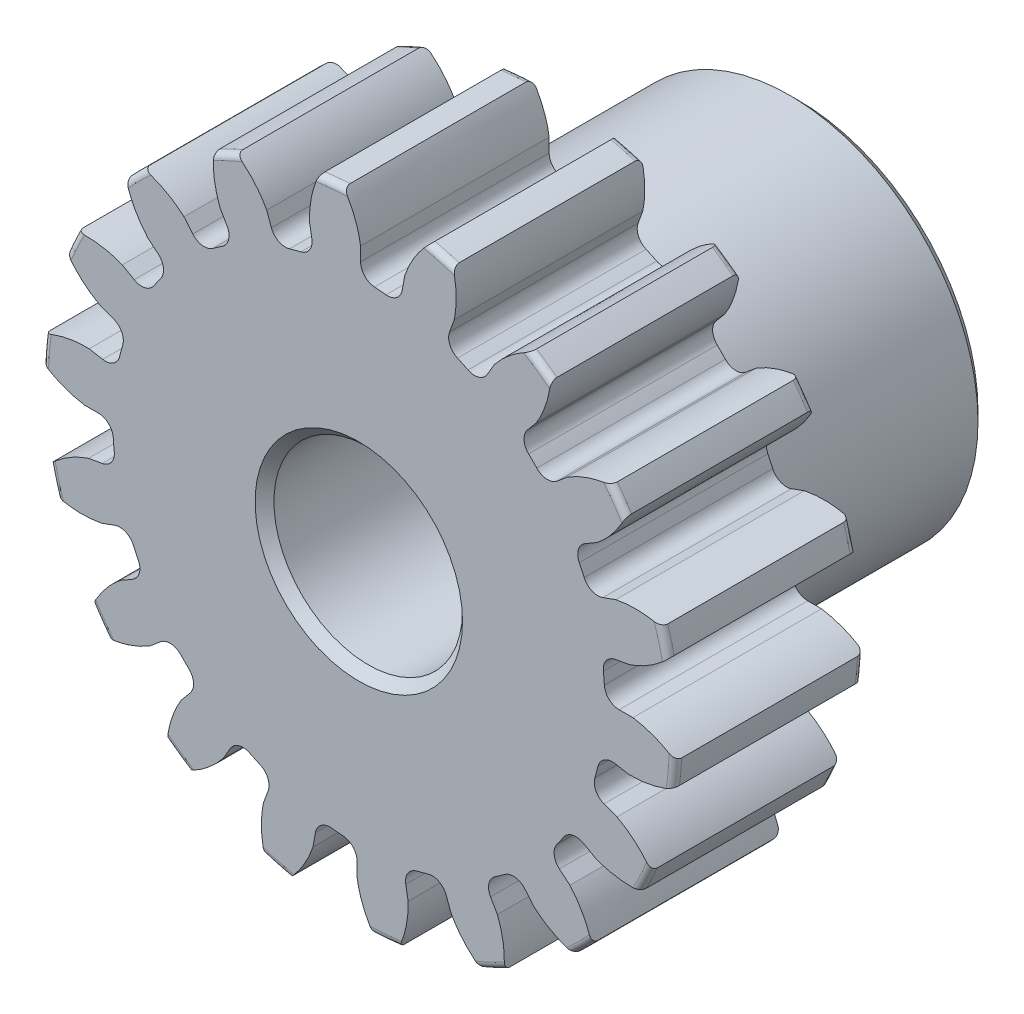
from build123d import *

# Parameters (mm, degrees)
SKETCH1_R                = 8.001
BOSS_EXTRUDE1_DEPTH      = 4.7625
SKETCH2_W                = 6.35
SKETCH2_H                = 4.7625
FILLET2_R                = 0.16002
CUT_EXTRUDE1_DEPTH       = 12.1125
FILLET1_R                = 0.374379236
CIRPATTERN1_COUNT        = 18
FILLET1_OF_CIRPATTERN1_R = 0.374379236
SKETCH5_R                = 2.38125
CUT_EXTRUDE2_DEPTH       = 12.1125
CHAMFER1_SIZE            = 0.238125


with BuildPart() as part:
    # Sketch1 → Boss-Extrude1 (new body)
    with BuildSketch(Plane.XY):
        Circle(SKETCH1_R)
    extrude(amount=-BOSS_EXTRUDE1_DEPTH)

    # Sketch2 → Revolve1 (revolve)
    with BuildSketch(Plane(origin=(0, 0, 0), x_dir=(0, 0, -1), z_dir=(1, 0, 0))):
        with Locations((7.9375, 2.38125)):
            Rectangle(SKETCH2_W, SKETCH2_H)
    revolve(axis=Axis((0, 0, -4.7625), (0, 0, -1)))

    # Fillet2
    fillet2_edges = [part.edges().sort_by_distance(p)[0] for p in [
        (-8.001, 0, 0),
        (-8.001, 0, -4.7625),
        (0, -4.7625, -4.7625),
    ]]
    fillet(fillet2_edges, radius=FILLET2_R)

    # Sketch4 → Cut-Extrude1 (cut, through all)
    with BuildSketch(Plane.XY):
        with BuildLine():
            Line((0.044804978, 6.922207442), (0.044804978, 6.213313455))
            ThreePointArc((0.044804978, 6.213313455), (0.541541292, 6.189830741), (1.034808769, 6.126699143))
            Line((1.034808769, 6.126699143), (1.157907203, 6.824823387))
            add(Edge.make_bspline(
                [(2.168123375, 8.144784029), (1.423960171, 7.618681923), (1.157907203, 6.824823387)],
                knots=[0, 0, 0, 1, 1, 1], degree=2))
            ThreePointArc((2.168123375, 8.144784029), (0.73458693, 8.396347295), (-0.720854378, 8.397537426))
            add(Edge.make_bspline(
                [(-0.720854378, 8.397537426), (-0.079353621, 7.750205147), (0.044804978, 6.922207442)],
                knots=[0, 0, 0, 1, 1, 1], degree=2))
        make_face()
    cut_extrude1 = extrude(amount=-CUT_EXTRUDE1_DEPTH, mode=Mode.SUBTRACT)

    # Fillet1
    fillet1_edges = [part.edges().sort_by_distance(p)[0] for p in [
        (1.034808769, 6.126699143, -2.38125),
        (0.044804978, 6.213313455, -2.38125),
    ]]
    fillet(fillet1_edges, radius=FILLET1_R)

    # CirPattern1: Cut-Extrude1 ×18 about axis
    cirpattern1_axis = Axis((0, 0, -4.7625), (0, 0, 1))
    for i in range(1, CIRPATTERN1_COUNT):
        add(cut_extrude1.rotate(cirpattern1_axis, i * 360 / CIRPATTERN1_COUNT), mode=Mode.SUBTRACT)

    # Fillet1 of CirPattern1
    fillet1_of_cirpattern1_edges = [part.edges().sort_by_distance(p)[0] for p in [
        (-1.123052354, 6.111139418, -2.38125),
        (-2.082975451, 5.853929009, -2.38125),
        (-3.14545679, 5.358486088, -2.38125),
        (-3.959518299, 4.78847433, -2.38125),
        (-4.788472714, 3.959520254, -2.38125),
        (-5.358484805, 3.145458977, -2.38125),
        (-5.853928159, 2.08297784, -2.38125),
        (-6.11113896, 1.123054848, -2.38125),
        (-6.213313473, -0.044802442, -2.38125),
        (-6.126699565, -1.034806269, -2.38125),
        (-5.823281484, -2.167178889, -2.38125),
        (-5.403289783, -3.067854478, -2.38125),
        (-4.730875805, -4.028161578, -2.38125),
        (-4.028163508, -4.730874161, -2.38125),
        (-3.067856684, -5.403288531, -2.38125),
        (-2.167181266, -5.823280599, -2.38125),
        (-1.034808769, -6.126699143, -2.38125),
        (-0.044804978, -6.213313455, -2.38125),
        (1.123052354, -6.111139418, -2.38125),
        (2.082975451, -5.853929009, -2.38125),
        (3.14545679, -5.358486088, -2.38125),
        (3.959518299, -4.78847433, -2.38125),
        (4.788472714, -3.959520254, -2.38125),
        (5.358484805, -3.145458977, -2.38125),
        (5.853928159, -2.08297784, -2.38125),
        (6.11113896, -1.123054848, -2.38125),
        (6.213313473, 0.044802442, -2.38125),
        (6.126699565, 1.034806269, -2.38125),
        (5.823281484, 2.167178889, -2.38125),
        (5.403289783, 3.067854478, -2.38125),
        (4.730875805, 4.028161578, -2.38125),
        (4.028163508, 4.730874161, -2.38125),
        (3.067856684, 5.403288531, -2.38125),
        (2.167181266, 5.823280599, -2.38125),
    ]]
    fillet(fillet1_of_cirpattern1_edges, radius=FILLET1_OF_CIRPATTERN1_R)

    # Sketch5 → Cut-Extrude2 (cut, through all)
    with BuildSketch(Plane.XY):
        Circle(SKETCH5_R)
    extrude(amount=-CUT_EXTRUDE2_DEPTH, mode=Mode.SUBTRACT)

    # Chamfer1
    chamfer1_edges = [part.edges().sort_by_distance(p)[0] for p in [
        (0, -4.7625, -11.1125),
        (-2.38125, 0, -11.1125),
        (-2.38125, 0, 0),
    ]]
    chamfer(chamfer1_edges, length=CHAMFER1_SIZE)


solid = part.part
